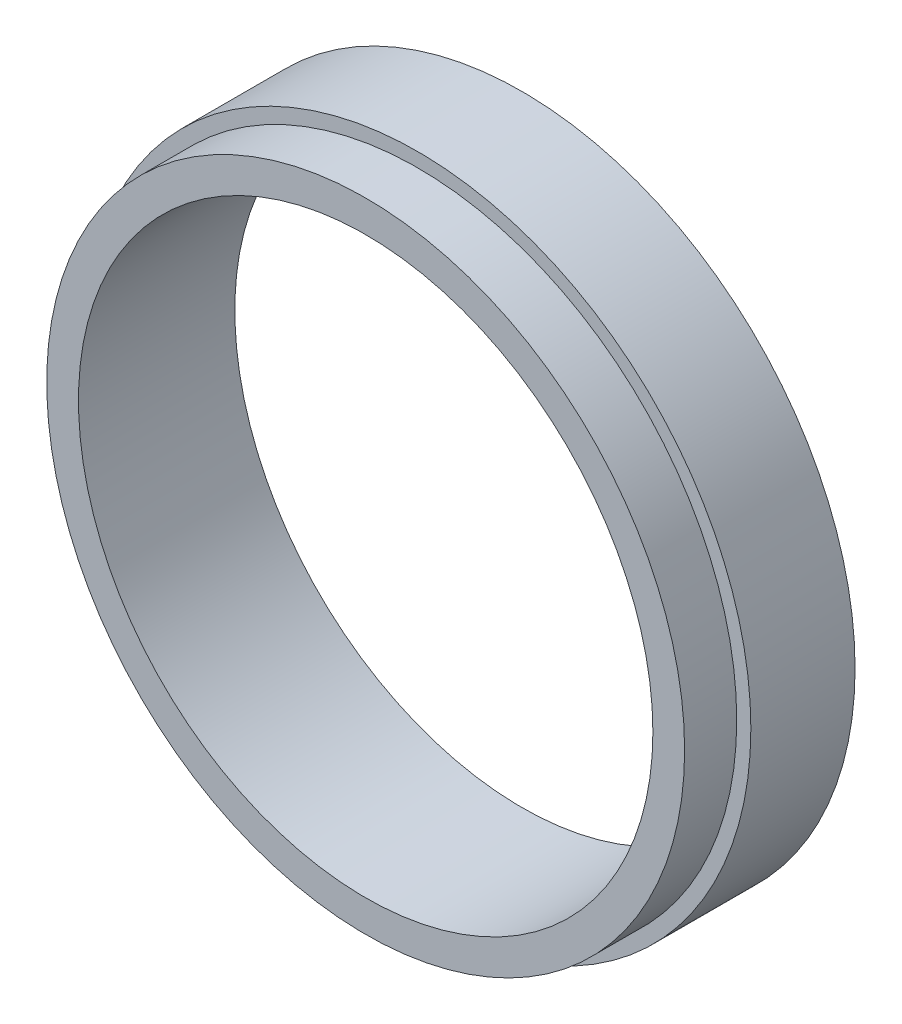
from build123d import *


with BuildPart() as part:
    # Sketch1 → Revolve1 (revolve)
    with BuildSketch(Plane(origin=(0, 0, 0), x_dir=(0, 0, -1), z_dir=(1, 0, 0))):
        Polygon((0, 17.5), (9.525, 17.5), (9.525, 20.294), (3.175, 20.294), (3.175, 19.4337), (0, 19.4337), align=None)
    revolve(axis=Axis((0, 0, 1000), (0, 0, -1)))


solid = part.part
